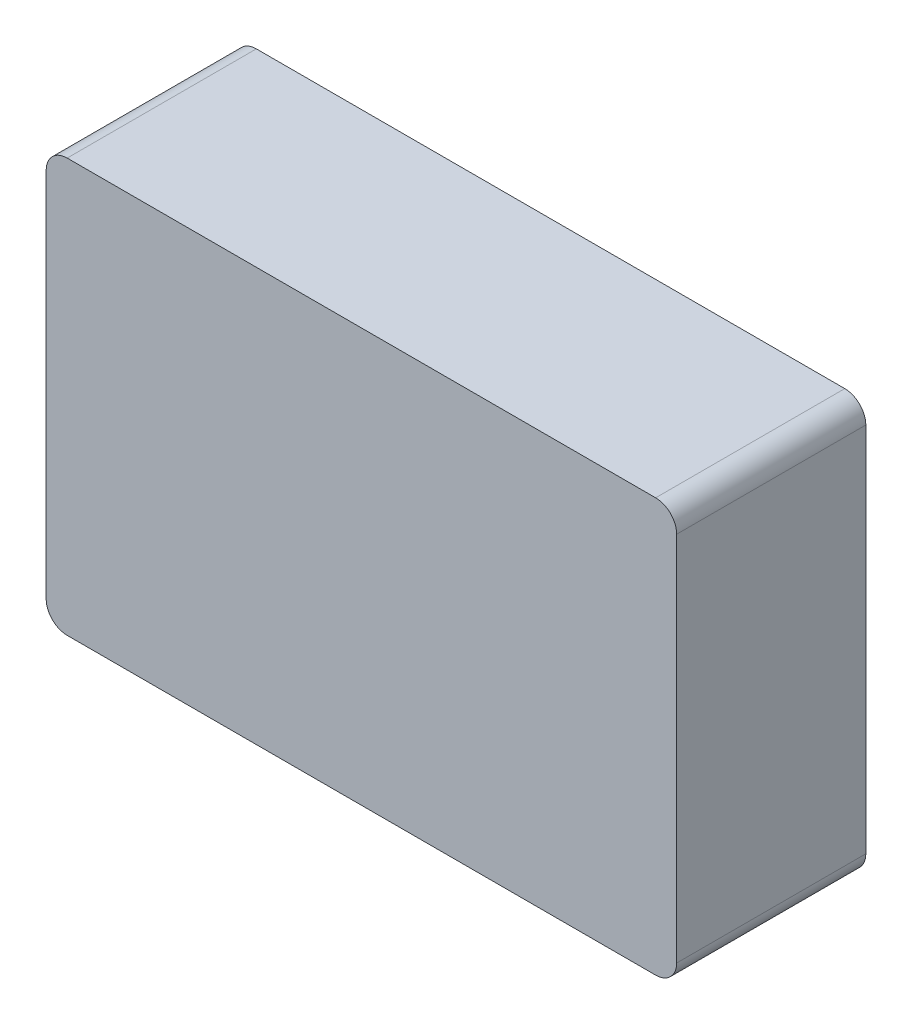
from build123d import *

# Parameters (mm, degrees)
BOSS_EXTRUDE1_DEPTH = 9


with BuildPart() as part:
    # Sketch2 → Boss-Extrude1 (new body)
    with BuildSketch(Plane.XY):
        with BuildLine():
            Line((-14, -9.834961348), (14, -9.834961348))
            ThreePointArc((14, -9.834961348), (14.707106781, -9.54206813), (15, -8.834961348))
            Line((15, -8.834961348), (15, 8.834961348))
            ThreePointArc((15, 8.834961348), (14.707106781, 9.54206813), (14, 9.834961348))
            Line((14, 9.834961348), (-14, 9.834961348))
            ThreePointArc((-14, 9.834961348), (-14.707106781, 9.54206813), (-15, 8.834961348))
            Line((-15, 8.834961348), (-15, -8.834961348))
            ThreePointArc((-15, -8.834961348), (-14.707106781, -9.54206813), (-14, -9.834961348))
        make_face()
    extrude(amount=BOSS_EXTRUDE1_DEPTH)


solid = part.part
